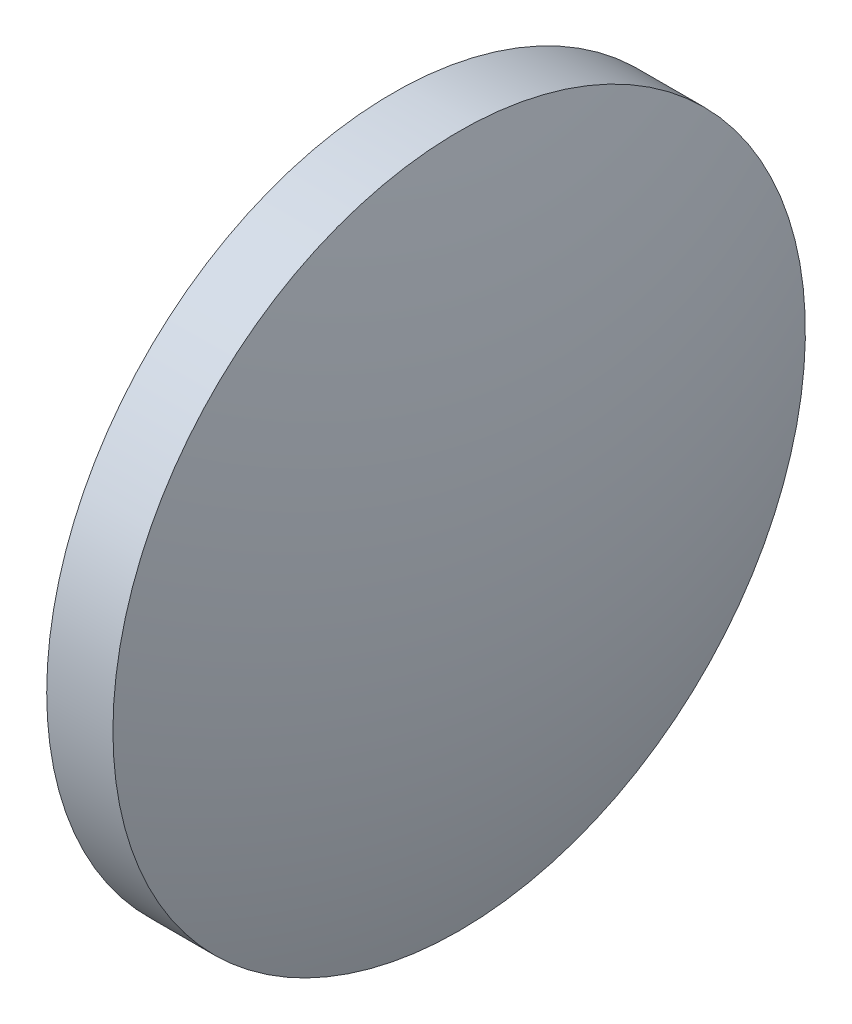
from build123d import *


with BuildPart() as part:
    # 草图1 → 旋转1 (revolve)
    with BuildSketch(Plane.XY, mode=Mode.PRIVATE) as revolve_1_sk:
        with BuildLine():
            Line((502.478097284, 80.199456852), (502.478097284, 88.199456852))
            Line((502.478097284, 88.199456852), (504.008097284, 88.199456852))
            ThreePointArc((504.008097284, 88.199456852), (504.958621726, 84.249546357), (505.278097284, 80.199456852))
            Line((505.278097284, 80.199456852), (502.478097284, 80.199456852))
        make_face()
    revolve(revolve_1_sk.sketch.rotate(Axis((500.830124811, 80.199456852, 0), (1, 0, 0)), 180), axis=Axis((500.830124811, 80.199456852, 0), (1, 0, 0)))  # turned: the seam where the file's is


solid = part.part
